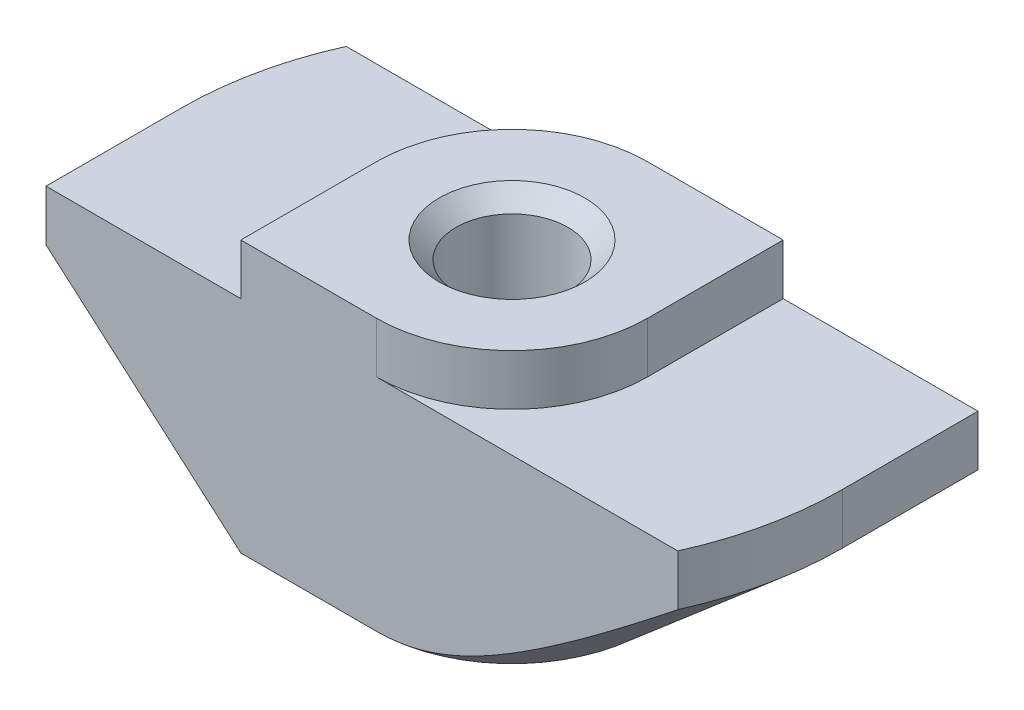
from build123d import *

# Parameters (mm, degrees)
EXTRUDE_1_DEPTH     = 4
CUT_EXTRUDE_1_DEPTH = 1.5
CUT_EXTRUDE_2_DEPTH = 7.5


with BuildPart() as part:
    # Эскиз1 → Бобышка-Вытянуть1 (new body, symmetric)
    with BuildSketch(Plane.XY):
        Polygon((4, 0), (-4, 0), (-4, -1.5), (-9.75, -1.5), (-9.75, -8), (9.75, -8), (9.75, -1.5), (4, -1.5), align=None)
    extrude(amount=EXTRUDE_1_DEPTH, both=True)

    # Эскиз3 → Отверстие обработанное метчиком M43 (revolve, cut)
    with BuildSketch(Plane(origin=(0, 0, 0), x_dir=(0, 0, 1), z_dir=(1, 0, 0))):
        Polygon((0, 0), (0, 8), (2.15, 8), (1.65, 7.5), (1.65, 0.5), (2.15, 0), align=None)
    revolve(axis=Axis((0, 6.35, 0), (0, -1, 0)), mode=Mode.SUBTRACT)

    # Эскиз4 → Вырез-Вытянуть1 (cut)
    with BuildSketch(Plane(origin=(0, 0, 0), x_dir=(1, 0, 0), z_dir=(0, 1, 0))):
        with BuildLine():
            Line((-4, 4), (-4, 0))
            ThreePointArc((-4, 0), (-2.828427125, 2.828427125), (0, 4))
            Line((0, 4), (-4, 4))
        make_face()
        with BuildLine():
            Line((0, -4), (4, -4))
            Line((4, -4), (4, 0))
            ThreePointArc((4, 0), (2.828427125, -2.828427125), (0, -4))
        make_face()
    extrude(amount=-CUT_EXTRUDE_1_DEPTH, mode=Mode.SUBTRACT)

    # Эскиз5 → Вырез-Вытянуть2 (cut, through all)
    with BuildSketch(Plane(origin=(0, -1.5, 0), x_dir=(1, 0, 0), z_dir=(0, 1, 0))):
        with BuildLine():
            Line((-9.75, 0), (-9.75, 4))
            Line((-9.75, 4), (-8.891709622, 4))
            ThreePointArc((-8.891709622, 4), (-9.533012871, 2.045523305), (-9.75, 0))
        make_face()
        with BuildLine():
            Line((9.75, 0), (9.75, -4))
            Line((9.75, -4), (8.891709622, -4))
            ThreePointArc((8.891709622, -4), (9.533012871, -2.045523305), (9.75, 0))
        make_face()
    extrude(amount=-CUT_EXTRUDE_2_DEPTH, mode=Mode.SUBTRACT)

    # Вырез-По траектории1: sweep along a path in Эскиз7
    with BuildLine(Plane.XZ.offset(8)) as sweep_1_path:
        Line((0, 9.75), (-9.75, 9.75))
        Line((-9.75, 9.75), (-9.75, 0))
        ThreePointArc((-9.75, 0), (-6.894291117, -6.894291117), (0, -9.75))
        Line((0, -9.75), (9.75, -9.75))
        Line((9.75, -9.75), (9.75, 0))
        ThreePointArc((9.75, 0), (6.894291117, 6.894291117), (0, 9.75))
    # Эскиз6 → Вырез-По траектории1 (sweep, cut)
    with BuildSketch(Plane.XY.offset(4)):
        Polygon((-9.75, -3), (-9.75, -8), (-4, -8), align=None)
    sweep(path=sweep_1_path.line, transition=Transition.RIGHT, mode=Mode.SUBTRACT)


solid = part.part
